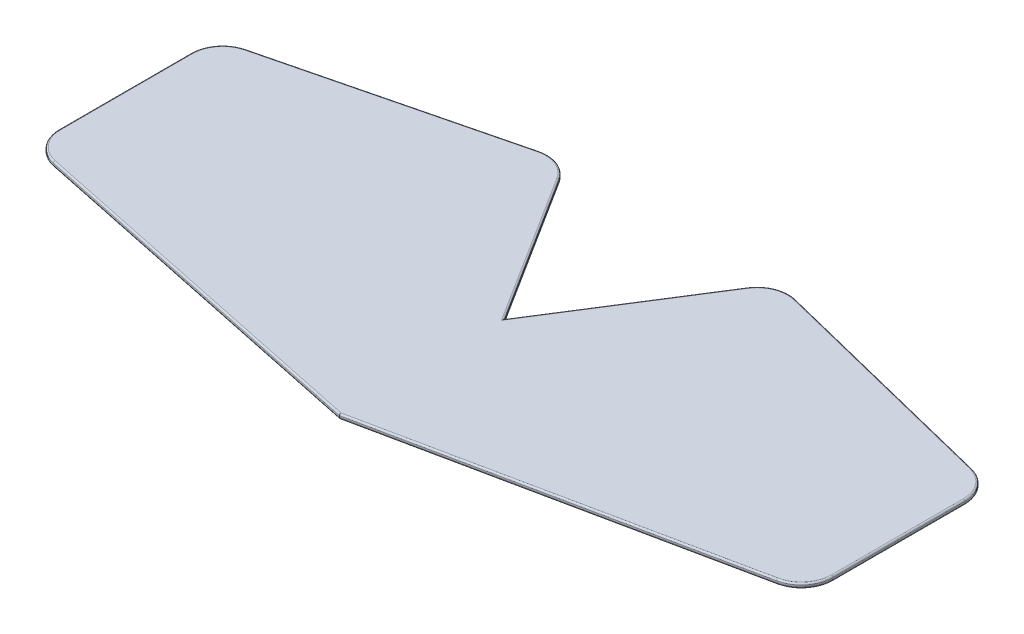
from build123d import *

# Parameters (mm, degrees)
BOSS_EXTRUDE1_DEPTH = 15
FILLET1_R           = 5


with BuildPart() as part:
    # Sketch1 → Boss-Extrude1 (new body)
    with BuildSketch(Plane(origin=(0, 0, 0), x_dir=(1, 0, 0), z_dir=(0, 1, 0))):
        with BuildLine():
            Line((0, 0), (-296.420139667, 468.96320604))
            ThreePointArc((-296.420139667, 468.96320604), (-343.696667359, 508.335758373), (-405.074608149, 512.580323398))
            Line((-405.074608149, 512.580323398), (-1144.124532862, 328.861698046))
            ThreePointArc((-1144.124532862, 328.861698046), (-1198.779608041, 293.408896337), (-1220, 231.815281758))
            Line((-1220, 231.815281758), (-1220, -183.740597223))
            ThreePointArc((-1220, -183.740597223), (-1197.607828507, -246.804255176), (-1140.459500912, -281.625268252))
            Line((-1140.459500912, -281.625268252), (0, -520))
            Line((0, -520), (1140.459500912, -281.625268252))
            ThreePointArc((1140.459500912, -281.625268252), (1197.607828507, -246.804255176), (1220, -183.740597223))
            Line((1220, -183.740597223), (1220, 231.815281758))
            ThreePointArc((1220, 231.815281758), (1198.779608041, 293.408896337), (1144.124532862, 328.861698046))
            Line((1144.124532862, 328.861698046), (405.074608149, 512.580323398))
            ThreePointArc((405.074608149, 512.580323398), (343.696667359, 508.335758373), (296.420139667, 468.96320604))
            Line((296.420139667, 468.96320604), (0, 0))
        make_face()
    extrude(amount=BOSS_EXTRUDE1_DEPTH)

    # Fillet1
    fillet1_edges = [part.edges().sort_by_distance(p)[0] for p in [
        (-343.696667359, 15, -508.335758373),
        (343.696667359, 0, -508.335758373),
        (774.599570506, 0, -420.721010722),
        (1198.779608041, 0, -293.408896337),
        (1220, 0, -24.037342268),
        (1197.607828507, 0, 246.804255176),
        (570.229750456, 0, 400.812634126),
        (-570.229750456, 0, 400.812634126),
        (-1197.607828507, 0, 246.804255176),
        (-774.599570506, 15, -420.721010722),
        (-1220, 0, -24.037342268),
        (-1198.779608041, 0, -293.408896337),
        (-774.599570506, 0, -420.721010722),
        (-343.696667359, 0, -508.335758373),
        (-148.210069834, 0, -234.48160302),
        (148.210069834, 0, -234.48160302),
        (-1198.779608041, 15, -293.408896337),
        (-1220, 15, -24.037342268),
        (-1197.607828507, 15, 246.804255176),
        (-570.229750456, 15, 400.812634126),
        (570.229750456, 15, 400.812634126),
        (1197.607828507, 15, 246.804255176),
        (1220, 15, -24.037342268),
        (1198.779608041, 15, -293.408896337),
        (148.210069834, 15, -234.48160302),
        (774.599570506, 15, -420.721010722),
        (343.696667359, 15, -508.335758373),
        (-148.210069834, 15, -234.48160302),
    ]]
    fillet(fillet1_edges, radius=FILLET1_R)


solid = part.part
